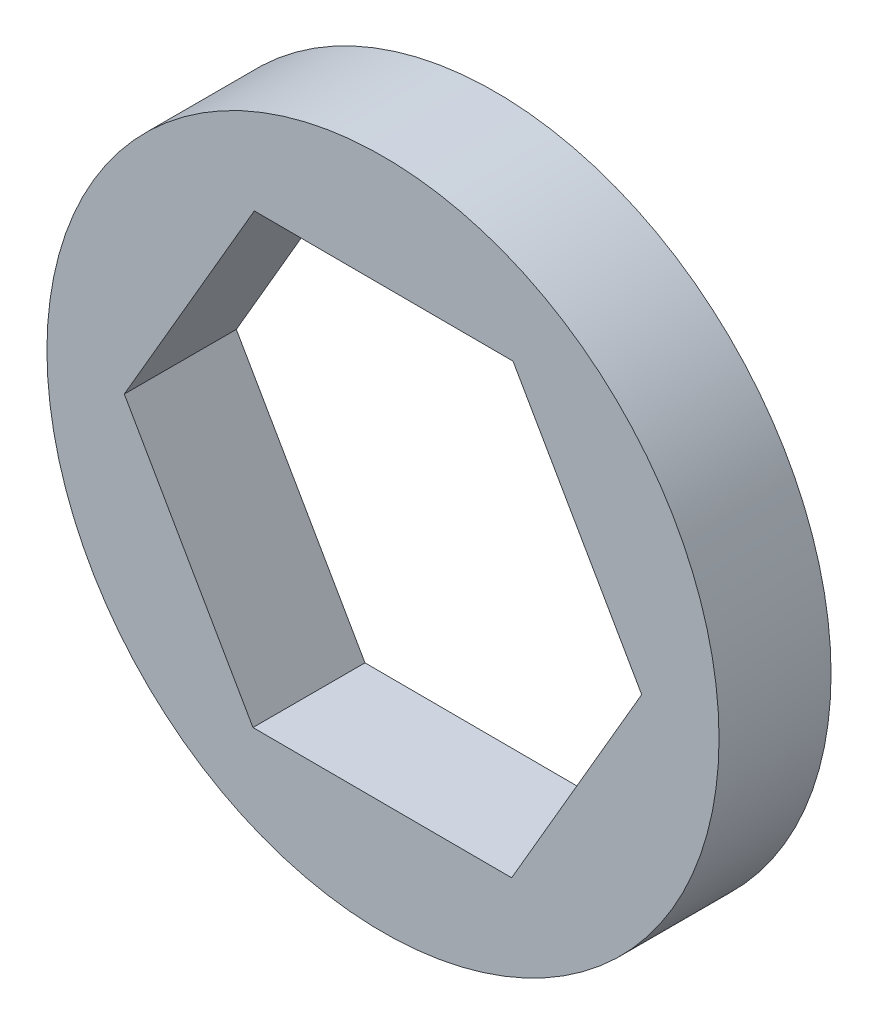
from build123d import *

# Parameters (mm, degrees)
SKETCH1_R           = 9.525
BOSS_EXTRUDE1_DEPTH = 3.175


with BuildPart() as part:
    # Sketch1 → Boss-Extrude1 (new body)
    with BuildSketch(Plane.XY):
        Circle(SKETCH1_R)
        Polygon((3.64699361, -6.361035367), (7.332315027, -0.022128569), (3.685321417, 6.338906797), (-3.64699361, 6.361035367), (-7.332315027, 0.022128569), (-3.685321417, -6.338906797), align=None, mode=Mode.SUBTRACT)
    extrude(amount=BOSS_EXTRUDE1_DEPTH)


solid = part.part
